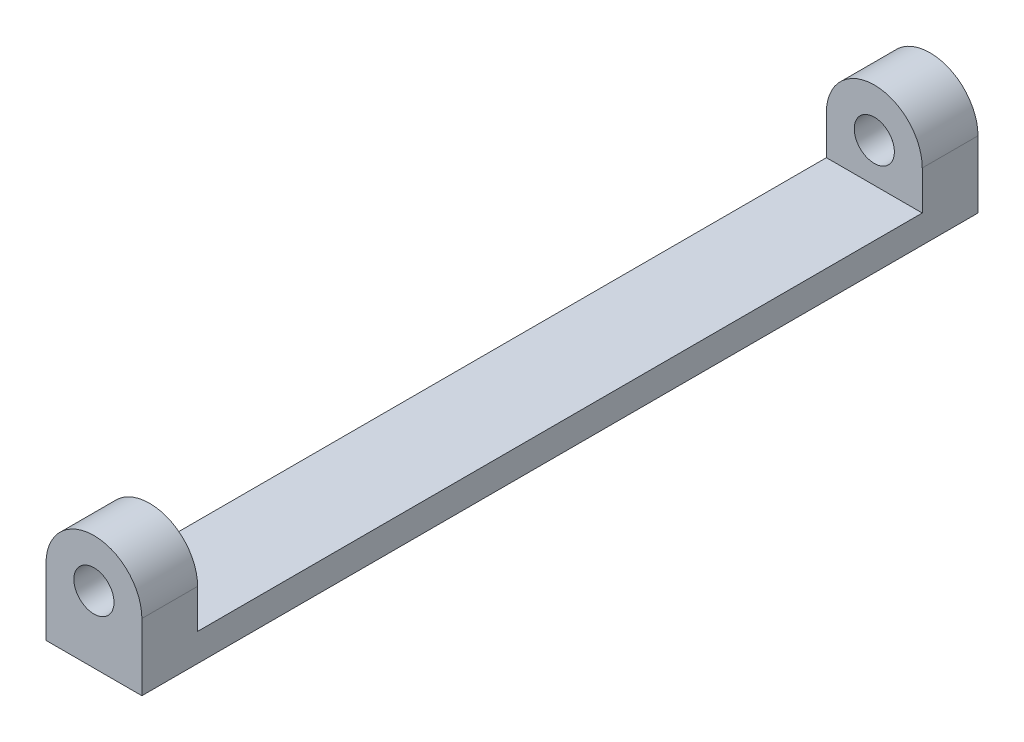
from build123d import *

# Parameters (mm, degrees)
SKETCH1_R           = 2.286
BOSS_EXTRUDE1_DEPTH = 95.25
SKETCH2_W           = 82.55
SKETCH2_H           = 9.906
CUT_EXTRUDE1_DEPTH  = 11.922


with BuildPart() as part:
    # Sketch1 → Boss-Extrude1 (new body)
    with BuildSketch(Plane.XY):
        with BuildLine():
            Line((0, 0), (10.922, 0))
            Line((10.922, 0), (10.922, 7.62))
            ThreePointArc((10.922, 7.62), (5.461, 13.081), (0, 7.62))
            Line((0, 7.62), (0, 0))
        make_face()
        with Locations((5.461, 7.62)):
            Circle(SKETCH1_R, mode=Mode.SUBTRACT)
    extrude(amount=BOSS_EXTRUDE1_DEPTH)

    # Sketch2 → Cut-Extrude1 (cut, through all)
    with BuildSketch(Plane(origin=(10.922, 0, 0), x_dir=(0, 0, -1), z_dir=(1, 0, 0))):
        with Locations((-47.625, 8.128)):
            Rectangle(SKETCH2_W, SKETCH2_H)
    extrude(amount=-CUT_EXTRUDE1_DEPTH, mode=Mode.SUBTRACT)


solid = part.part
